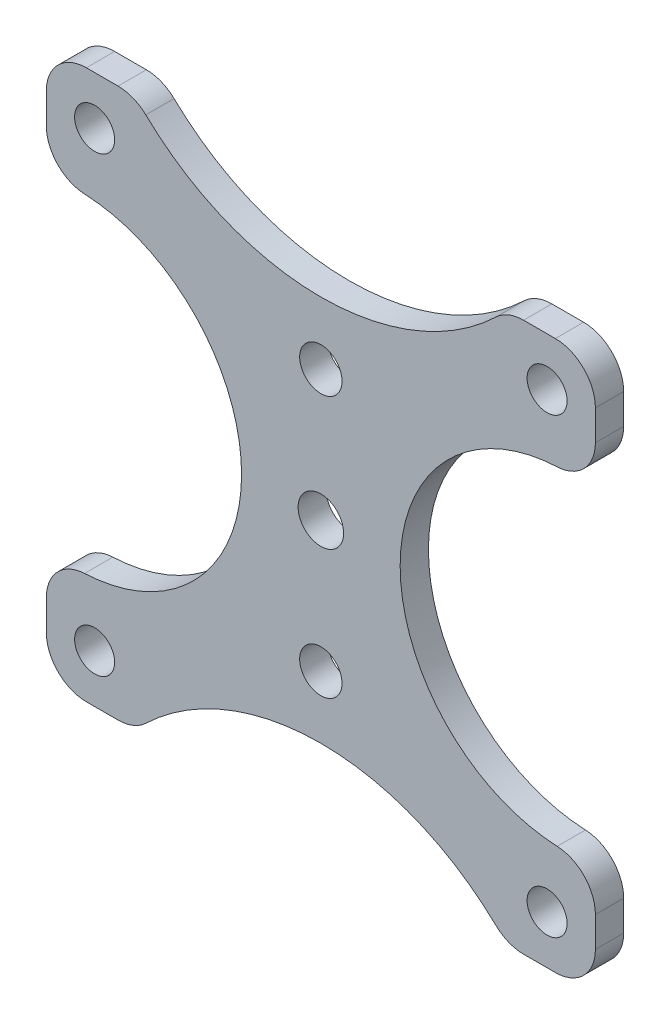
from build123d import *

# Parameters (mm, degrees)
SKETCH1_W                      = 61.6458
SKETCH1_H                      = 61.6458
BOSS_EXTRUDE1_DEPTH            = 3.175
F_3_16_0_1875_DIAMETER_HOLE1_D = 4.7625
F_8_CLEARANCE_HOLE1_D          = 4.4958
F_10_CLEARANCE_HOLE2_D         = 5.1054
FILLET1_R                      = 4.4958
SKETCH9_R                      = 28.452559636
CUT_EXTRUDE2_DEPTH             = 44.70563984
SKETCH9_4_R                    = 18.465762264
CUT_EXTRUDE3_DEPTH             = 44.70563984
FILLET3_R                      = 4.4958


with BuildPart() as part:
    # Sketch1 → Boss-Extrude1 (new body)
    with BuildSketch(Plane.XY):
        Rectangle(SKETCH1_W, SKETCH1_H)
    extrude(amount=BOSS_EXTRUDE1_DEPTH)

    # 3_16 _0.1875_ Diameter Hole1 (through all)
    with Locations(Plane.XY.offset(3.175)):
        with Locations((0, -14.685), (0, 14.685)):
            Hole(F_3_16_0_1875_DIAMETER_HOLE1_D / 2)

    # 8 Clearance Hole1 (through all)
    with Locations(Plane.XY.offset(3.175)):
        with Locations((-25.4, 25.4), (-25.4, -25.4), (25.4, -25.4), (25.4, 25.4)):
            Hole(F_8_CLEARANCE_HOLE1_D / 2)

    # 10 Clearance Hole2 (through all)
    with Locations(Plane.XY.offset(3.175)):
        with Locations((0, 0)):
            Hole(F_10_CLEARANCE_HOLE2_D / 2)

    # Fillet1
    fillet1_edges = [part.edges().sort_by_distance(p)[0] for p in [
        (-30.8229, -30.8229, 1.5875),
        (30.8229, -30.8229, 1.5875),
        (30.8229, 30.8229, 1.5875),
        (-30.8229, 30.8229, 1.5875),
    ]]
    fillet(fillet1_edges, radius=FILLET1_R)

    # Sketch9 → Cut-Extrude2 (cut, through all)
    with BuildSketch(Plane.XY.offset(3.175)):
        with Locations((0, 50.147959636)):
            Circle(SKETCH9_R)
    cut_extrude2 = extrude(amount=-CUT_EXTRUDE2_DEPTH, mode=Mode.SUBTRACT)

    # Sketch9_4 → Cut-Extrude3 (cut, through all)
    with BuildSketch(Plane.XY.offset(3.175)):
        with Locations((27.368462264, 0)):
            Circle(SKETCH9_4_R)
    cut_extrude3 = extrude(amount=-CUT_EXTRUDE3_DEPTH, mode=Mode.SUBTRACT)

    # Mirror1: Cut-Extrude2 across plane
    add(cut_extrude2.mirror(Plane.ZX), mode=Mode.SUBTRACT)

    # Mirror2: Cut-Extrude3 across plane
    add(cut_extrude3.mirror(Plane(origin=(0, 0, 0), x_dir=(0, 0, 1), z_dir=(1, 0, 0))), mode=Mode.SUBTRACT)

    # Fillet3
    fillet3_edges = [part.edges().sort_by_distance(p)[0] for p in [
        (-20.882773281, 30.8229, 1.5875),
        (20.882773281, 30.8229, 1.5875),
        (-30.8229, 18.139769456, 1.5875),
        (-30.8229, -18.139769456, 1.5875),
        (-20.882773281, -30.8229, 1.5875),
        (20.882773281, -30.8229, 1.5875),
        (30.8229, -18.139769456, 1.5875),
        (30.8229, 18.139769456, 1.5875),
    ]]
    fillet(fillet3_edges, radius=FILLET3_R)


solid = part.part
